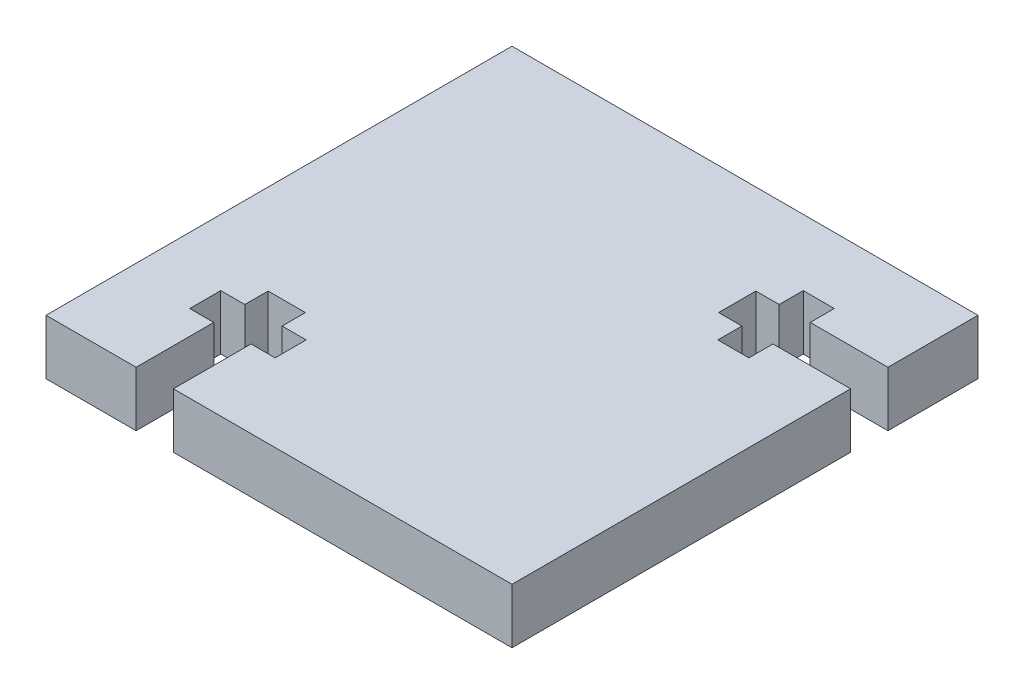
from build123d import *

# Parameters (mm, degrees)
BOSS_EXTRUDE1_DEPTH = 4.4958


with BuildPart() as part:
    # Sketch1 → Boss-Extrude1 (new body)
    with BuildSketch(Plane(origin=(0, 0, 0), x_dir=(1, 0, 0), z_dir=(0, 1, 0))):
        Polygon((-30.734, 0), (-30.734, 6.35), (-32.7025, 6.35), (-32.7025, 8.89), (-30.734, 8.89), (-30.734, 10.795), (-27.686, 10.795), (-27.686, 8.89), (-25.7175, 8.89), (-25.7175, 6.35), (-27.686, 6.35), (-27.686, 0), (0, 0), (0, 27.686), (-6.35, 27.686), (-6.35, 25.7175), (-8.89, 25.7175), (-8.89, 27.686), (-10.795, 27.686), (-10.795, 30.734), (-8.89, 30.734), (-8.89, 32.7025), (-6.35, 32.7025), (-6.35, 30.734), (0, 30.734), (0, 38.1), (-38.1, 38.1), (-38.1, 0), align=None)
    extrude(amount=BOSS_EXTRUDE1_DEPTH)


solid = part.part
